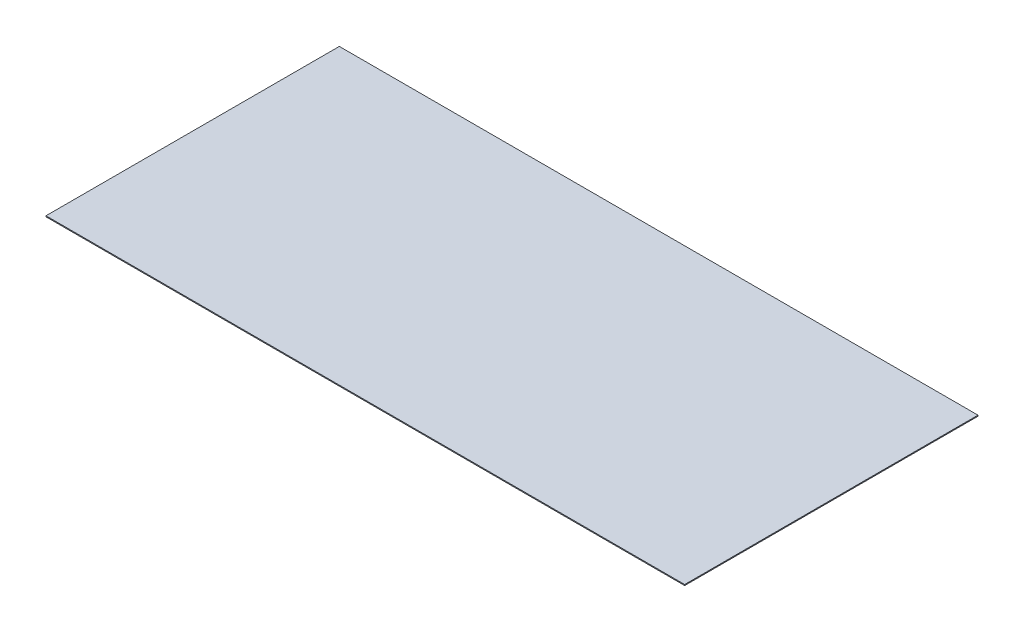
from build123d import *

# Parameters (mm, degrees)
SKETCH1_W           = 675
SKETCH1_H           = 310
BOSS_EXTRUDE2_DEPTH = 1


with BuildPart() as part:
    # Sketch1 → Boss-Extrude2 (new body)
    with BuildSketch(Plane(origin=(0, 0, 0), x_dir=(1, 0, 0), z_dir=(0, 1, 0))):
        Rectangle(SKETCH1_W, SKETCH1_H)
    extrude(amount=BOSS_EXTRUDE2_DEPTH)


solid = part.part
